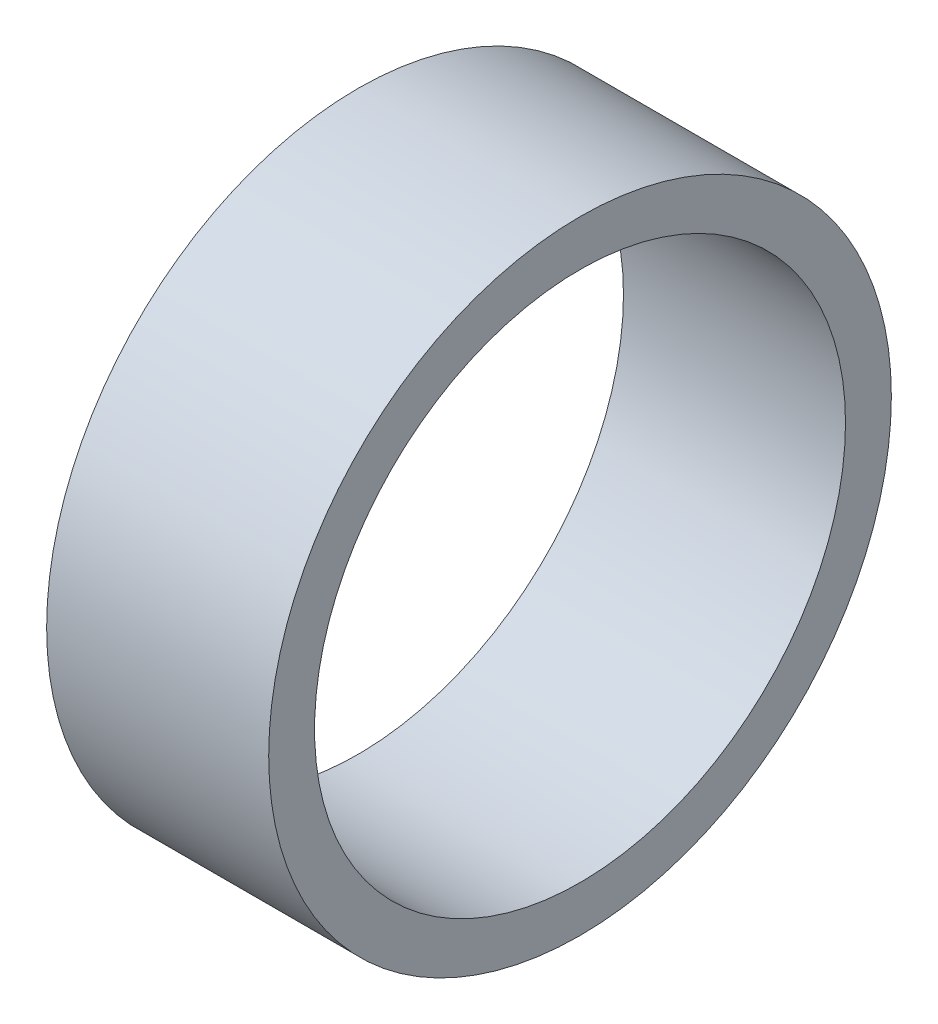
from build123d import *

# Parameters (mm, degrees)
SKETCH1_R           = 32.25
SKETCH1_R_2         = 27.5
BOSS_EXTRUDE1_DEPTH = 23


with BuildPart() as part:
    # Sketch1 → Boss-Extrude1 (new body)
    with BuildSketch(Plane(origin=(0, 0, 0), x_dir=(0, 0, -1), z_dir=(1, 0, 0))):
        Circle(SKETCH1_R)
        Circle(SKETCH1_R_2, mode=Mode.SUBTRACT)
    extrude(amount=BOSS_EXTRUDE1_DEPTH)


solid = part.part
